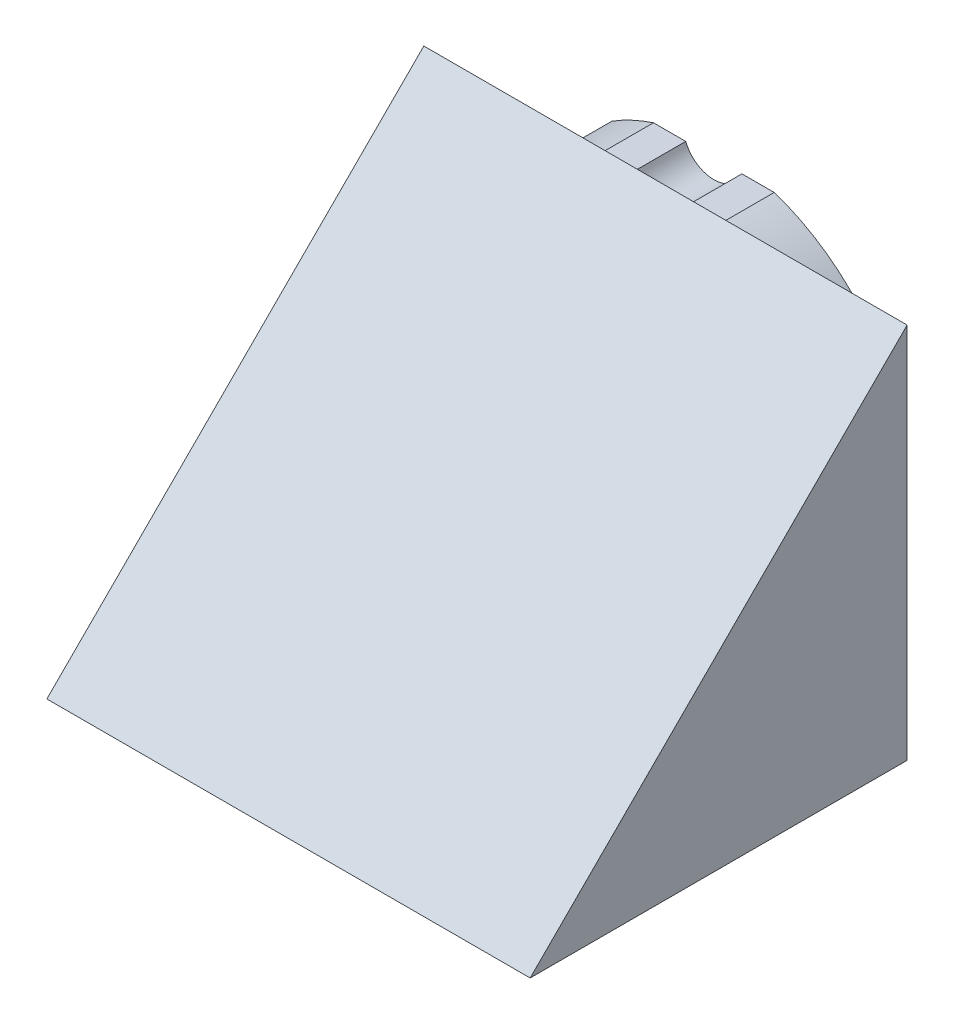
from build123d import *

# Parameters (mm, degrees)
ESTRUSIONE_ESTRUSIONE2_DEPTH = 10
ESTRUSIONE_ESTRUSIONE3_DEPTH = 50


with BuildPart() as part:
    # Schizzo4 → Estrusione-Estrusione2 (new body)
    with BuildSketch(Plane.XY):
        with BuildLine():
            ThreePointArc((5.811411188, 38), (0, 34.05), (-5.811411188, 38))
            Line((-5.811411188, 38), (-12.489995997, 38))
            ThreePointArc((-12.489995997, 38), (-16.909196271, 36.250228709), (-21.089648938, 33.988626151))
            Line((-21.089648938, 33.988626151), (-17.322367371, 29.336420856))
            ThreePointArc((-17.322367371, 29.336420856), (-16.844140316, 27.721953377), (-17.647583626, 26.242194881))
            Line((-17.647583626, 26.242194881), (-21.99960101, 22.718000691))
            ThreePointArc((-21.99960101, 22.718000691), (-23.61406849, 22.239773636), (-25.093826986, 23.043216946))
            Line((-25.093826986, 23.043216946), (-28.861108553, 27.695422241))
            ThreePointArc((-28.861108553, 27.695422241), (-38.449109313, 11.03023087), (-39.153963342, -8.183346174))
            Line((-39.153963342, -8.183346174), (-35.814606143, -13.967282507))
            ThreePointArc((-35.814606143, -13.967282507), (-29.487341226, -17.025), (-30.002912658, -24.033430901))
            Line((-30.002912658, -24.033430901), (-26.663967345, -29.816653826))
            ThreePointArc((-26.663967345, -29.816653826), (0, -40), (26.663967345, -29.816653826))
            Line((26.663967345, -29.816653826), (30.002912658, -24.033430901))
            ThreePointArc((30.002912658, -24.033430901), (29.487341226, -17.025), (35.814606143, -13.967282507))
            Line((35.814606143, -13.967282507), (39.153963342, -8.183346174))
            ThreePointArc((39.153963342, -8.183346174), (34.641016151, 20), (12.489995997, 38))
            Line((12.489995997, 38), (5.811411188, 38))
        make_face()
        with BuildLine():
            ThreePointArc((-9, -33.621), (-10.621, -32), (-9, -30.379))
            ThreePointArc((-9, -30.379), (-7.379, -32), (-9, -33.621))
        make_face(mode=Mode.SUBTRACT)
        with BuildLine():
            ThreePointArc((9, -33.621), (7.379, -32), (9, -30.379))
            ThreePointArc((9, -30.379), (10.621, -32), (9, -33.621))
        make_face(mode=Mode.SUBTRACT)
        with BuildLine():
            ThreePointArc((-30.3, 21.75), (-26.05, 17.5), (-30.3, 13.25))
            ThreePointArc((-30.3, 13.25), (-34.55, 17.5), (-30.3, 21.75))
        make_face(mode=Mode.SUBTRACT)
        with BuildLine():
            ThreePointArc((30.3, 21.75), (34.55, 17.5), (30.3, 13.25))
            ThreePointArc((30.3, 13.25), (26.05, 17.5), (30.3, 21.75))
        make_face(mode=Mode.SUBTRACT)
        with BuildLine():
            ThreePointArc((0, -30.75), (4.25, -35), (0, -39.25))
            ThreePointArc((0, -39.25), (-4.25, -35), (0, -30.75))
        make_face(mode=Mode.SUBTRACT)
        with BuildLine():
            ThreePointArc((-35, -3.5), (-38.5, 0), (-35, 3.5))
            ThreePointArc((-35, 3.5), (-31.5, 0), (-35, -3.5))
        make_face(mode=Mode.SUBTRACT)
        with BuildLine():
            ThreePointArc((35, -3.5), (31.5, 0), (35, 3.5))
            ThreePointArc((35, 3.5), (38.5, 0), (35, -3.5))
        make_face(mode=Mode.SUBTRACT)
        with BuildLine():
            ThreePointArc((0, 27.5), (27.5, 0), (0, -27.5))
            ThreePointArc((0, -27.5), (-27.5, 0), (0, 27.5))
        make_face(mode=Mode.SUBTRACT)
        with BuildLine():
            ThreePointArc((25, 22.933), (22.933, 25), (25, 27.067))
            ThreePointArc((25, 27.067), (27.067, 25), (25, 22.933))
        make_face(mode=Mode.SUBTRACT)
        with BuildLine():
            ThreePointArc((0, -27.5), (-27.5, 0), (0, 27.5))
            ThreePointArc((0, 27.5), (27.5, 0), (0, -27.5))
        make_face()
        with BuildLine():
            ThreePointArc((-35, 3.5), (-31.5, 0), (-35, -3.5))
            ThreePointArc((-35, -3.5), (-38.5, 0), (-35, 3.5))
        make_face()
        with BuildLine():
            ThreePointArc((9, -30.379), (10.621, -32), (9, -33.621))
            ThreePointArc((9, -33.621), (7.379, -32), (9, -30.379))
        make_face()
        with BuildLine():
            ThreePointArc((-9, -30.379), (-7.379, -32), (-9, -33.621))
            ThreePointArc((-9, -33.621), (-10.621, -32), (-9, -30.379))
        make_face()
        with BuildLine():
            ThreePointArc((35, 3.5), (38.5, 0), (35, -3.5))
            ThreePointArc((35, -3.5), (31.5, 0), (35, 3.5))
        make_face()
        with BuildLine():
            ThreePointArc((25, 27.067), (27.067, 25), (25, 22.933))
            ThreePointArc((25, 22.933), (22.933, 25), (25, 27.067))
        make_face()
    extrude(amount=ESTRUSIONE_ESTRUSIONE2_DEPTH)

    # Schizzo5 → Estrusione-Estrusione3 (add, symmetric)
    with BuildSketch(Plane(origin=(0, 0, 0), x_dir=(0, 0, -1), z_dir=(1, 0, 0))):
        Polygon((-10, 38), (-10, -40), (-88, -40), align=None)
    extrude(amount=ESTRUSIONE_ESTRUSIONE3_DEPTH, both=True)


solid = part.part
